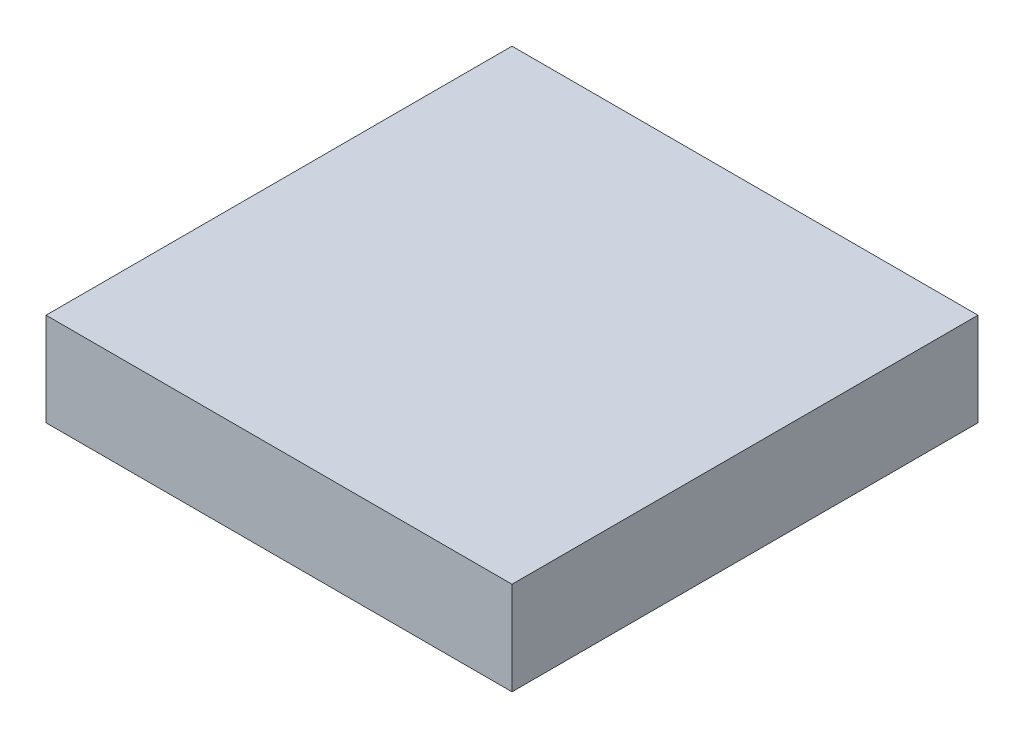
from build123d import *

# Parameters (mm, degrees)
SKETCH1_W           = 10
SKETCH1_H           = 10
BOSS_EXTRUDE1_DEPTH = 1
SKETCH1_4_W         = 10
SKETCH1_4_H         = 10
SKETCH1_4_W_2       = 8
SKETCH1_4_H_2       = 8
SKETCH1_4_R         = 2.035533906
SKETCH1_4_R_2       = 1.5
BOSS_EXTRUDE3_DEPTH = 1


with BuildPart() as part:
    # Sketch1 → Boss-Extrude1 (new body)
    with BuildSketch(Plane(origin=(0, 0, 0), x_dir=(1, 0, 0), z_dir=(0, 1, 0))):
        with Locations((5, 5)):
            Rectangle(SKETCH1_W, SKETCH1_H)
    extrude(amount=BOSS_EXTRUDE1_DEPTH)

    # Sketch1_4 → Boss-Extrude3 (add)
    # profile 1 of 2: a face of its own
    with BuildSketch(Plane(origin=(0, 0, 0), x_dir=(1, 0, 0), z_dir=(0, 1, 0))):
        with Locations((5, 5)):
            Rectangle(SKETCH1_4_W, SKETCH1_4_H)
        with Locations((5, 5)):
            Rectangle(SKETCH1_4_W_2, SKETCH1_4_H_2, mode=Mode.SUBTRACT)
    # profile 2 of 2: a face of its own
    with BuildSketch(Plane(origin=(0, 0, 0), x_dir=(1, 0, 0), z_dir=(0, 1, 0))):
        with Locations((5, 5)):
            Circle(SKETCH1_4_R)
        with Locations((5, 5)):
            Circle(SKETCH1_4_R_2, mode=Mode.SUBTRACT)
    extrude(amount=-BOSS_EXTRUDE3_DEPTH)


solid = part.part
